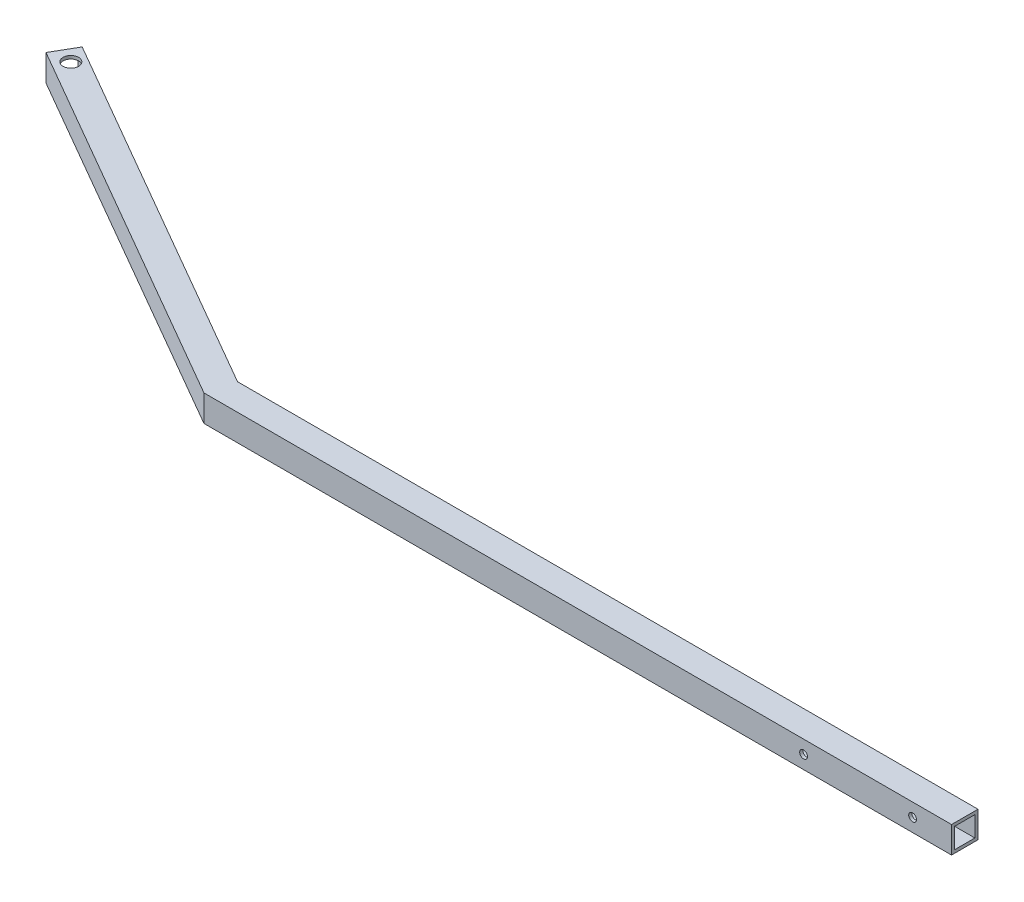
from build123d import *

# Parameters (mm, degrees)
BOSS_EXTRUDE1_DEPTH          = 21.59
SHELL3_T                     = -2.54
SKETCH2_R                    = 3.175
PIN_HOLES_DEPTH              = 195.673850517
SKETCH3_R                    = 6.35
TOW_HITCH_ADAPTOR_HOLE_DEPTH = 22.59


with BuildPart() as part:
    # Sketch1 → Boss-Extrude1 (new body)
    with BuildSketch(Plane(origin=(0, 0, 0), x_dir=(1, 0, 0), z_dir=(0, 1, 0))):
        Polygon((0, 0), (-609.6, 0), (-914.4, 175.976362049), (-903.605, 194.673850517), (-603.814976935, 21.59), (0, 21.59), align=None)
    extrude(amount=-BOSS_EXTRUDE1_DEPTH)

    # Shell3
    shell3_openings = [part.faces().sort_by_distance(p)[0] for p in [
        (-909.0025, -10.795, -185.325106283),
        (0, -10.795, -10.795),
    ]]
    offset(amount=SHELL3_T, openings=shell3_openings, kind=Kind.INTERSECTION)

    # Sketch2 → PIN HOLES (cut, through all)
    with BuildSketch(Plane.XY):
        with Locations((-120.65, -10.791269693)):
            Circle(SKETCH2_R)
        with Locations((-31.75, -10.791269693)):
            Circle(SKETCH2_R)
    extrude(amount=-PIN_HOLES_DEPTH, mode=Mode.SUBTRACT)

    # Sketch3 → TOW HITCH ADAPTOR HOLE (cut, through all)
    with BuildSketch(Plane(origin=(0, 0, 0), x_dir=(1, 0, 0), z_dir=(0, 1, 0))):
        with Locations((-897.686477372, 179.525032414)):
            Circle(SKETCH3_R)
    extrude(amount=-TOW_HITCH_ADAPTOR_HOLE_DEPTH, mode=Mode.SUBTRACT)


solid = part.part
